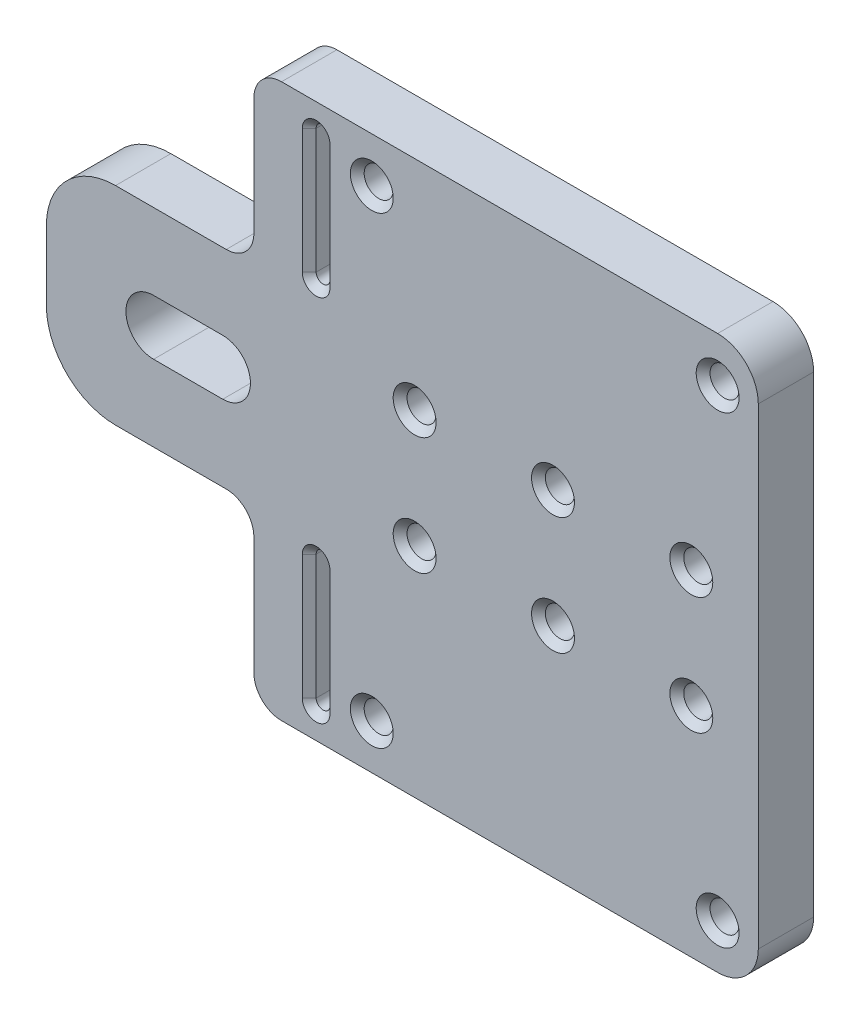
from build123d import *

# Parameters (mm, degrees)
MODEL_R            = 2.1
BOSS_EXTRU_1_DEPTH = 8
CHANFREIN1_SIZE    = 1


with BuildPart() as part:
    # Model → Boss.-Extru.1 (new body)
    with BuildSketch(Plane.XY):
        with BuildLine():
            Line((-24.192398664, -96.552630985), (-24.192398664, -106.552630985))
            ThreePointArc((-24.192398664, -106.552630985), (-21.263466476, -113.623698797), (-14.192398664, -116.552630985))
            Line((-14.192398664, -116.552630985), (1.807601336, -116.552630985))
            ThreePointArc((1.807601336, -116.552630985), (4.636028461, -117.72420386), (5.807601336, -120.552630985))
            Line((5.807601336, -120.552630985), (5.807601336, -137.552630985))
            ThreePointArc((5.807601336, -137.552630985), (6.979174211, -140.38105811), (9.807601336, -141.552630985))
            Line((9.807601336, -141.552630985), (72.853374331, -141.552630985))
            ThreePointArc((72.853374331, -141.552630985), (77.007626671, -139.831883325), (78.728374331, -135.677630985))
            Line((78.728374331, -135.677630985), (78.728374331, -67.427630985))
            ThreePointArc((78.728374331, -67.427630985), (77.007626671, -63.273378646), (72.853374331, -61.552630985))
            Line((72.853374331, -61.552630985), (9.807601336, -61.552630985))
            ThreePointArc((9.807601336, -61.552630985), (6.979174211, -62.72420386), (5.807601336, -65.552630985))
            Line((5.807601336, -65.552630985), (5.807601336, -82.552630985))
            ThreePointArc((5.807601336, -82.552630985), (4.636028461, -85.38105811), (1.807601336, -86.552630985))
            Line((1.807601336, -86.552630985), (-14.192398664, -86.552630985))
            ThreePointArc((-14.192398664, -86.552630985), (-21.263466476, -89.481563173), (-24.192398664, -96.552630985))
        make_face()
        with Locations((22.853374331, -68.052630985)):
            Circle(MODEL_R, mode=Mode.SUBTRACT)
        with Locations((72.853374331, -68.052630985)):
            Circle(MODEL_R, mode=Mode.SUBTRACT)
        with Locations((29.048492507, -93.052630985)):
            Circle(MODEL_R, mode=Mode.SUBTRACT)
        with Locations((29.048492507, -110.052630985)):
            Circle(MODEL_R, mode=Mode.SUBTRACT)
        with Locations((49.048492507, -93.052630985)):
            Circle(MODEL_R, mode=Mode.SUBTRACT)
        with Locations((49.048492507, -110.052630985)):
            Circle(MODEL_R, mode=Mode.SUBTRACT)
        with Locations((69.048492507, -93.052630985)):
            Circle(MODEL_R, mode=Mode.SUBTRACT)
        with Locations((69.048492507, -110.052630985)):
            Circle(MODEL_R, mode=Mode.SUBTRACT)
        with Locations((22.853374331, -135.052630985)):
            Circle(MODEL_R, mode=Mode.SUBTRACT)
        with Locations((72.853374331, -135.052630985)):
            Circle(MODEL_R, mode=Mode.SUBTRACT)
        with BuildLine():
            Line((15.807601336, -137.214613672), (15.807601336, -119.214613672))
            ThreePointArc((15.807601336, -119.214613672), (14.807601336, -118.214613672), (13.807601336, -119.214613672))
            Line((13.807601336, -119.214613672), (13.807601336, -137.214613672))
            ThreePointArc((13.807601336, -137.214613672), (14.807601336, -138.214613672), (15.807601336, -137.214613672))
        make_face(mode=Mode.SUBTRACT)
        with BuildLine():
            Line((15.807601336, -65.890648299), (15.807601336, -83.890648299))
            ThreePointArc((15.807601336, -83.890648299), (14.807601336, -84.890648299), (13.807601336, -83.890648299))
            Line((13.807601336, -83.890648299), (13.807601336, -65.890648299))
            ThreePointArc((13.807601336, -65.890648299), (14.807601336, -64.890648299), (15.807601336, -65.890648299))
        make_face(mode=Mode.SUBTRACT)
        with BuildLine():
            Line((-8.692398664, -97.552630985), (1.307601336, -97.552630985))
            ThreePointArc((1.307601336, -97.552630985), (5.307601336, -101.552630985), (1.307601336, -105.552630985))
            Line((1.307601336, -105.552630985), (-8.692398664, -105.552630985))
            ThreePointArc((-8.692398664, -105.552630985), (-12.692398664, -101.552630985), (-8.692398664, -97.552630985))
        make_face(mode=Mode.SUBTRACT)
    extrude(amount=BOSS_EXTRU_1_DEPTH)

    # Chanfrein1
    chanfrein1_edges = [part.edges().sort_by_distance(p)[0] for p in [
        (14.807601336, -118.214613672, 0),
        (13.807601336, -128.214613672, 0),
        (14.807601336, -138.214613672, 0),
        (15.807601336, -128.214613672, 0),
        (14.807601336, -118.214613672, 8),
        (13.807601336, -128.214613672, 8),
        (14.807601336, -138.214613672, 8),
        (15.807601336, -128.214613672, 8),
        (20.753374331, -68.052630985, 8),
        (70.753374331, -68.052630985, 8),
        (26.948492507, -93.052630985, 8),
        (26.948492507, -110.052630985, 8),
        (46.948492507, -93.052630985, 8),
        (46.948492507, -110.052630985, 8),
        (66.948492507, -93.052630985, 8),
        (66.948492507, -110.052630985, 8),
        (20.753374331, -135.052630985, 8),
        (70.753374331, -135.052630985, 8),
        (14.807601336, -64.890648299, 0),
        (13.807601336, -74.890648299, 0),
        (14.807601336, -84.890648299, 0),
        (15.807601336, -74.890648299, 0),
        (14.807601336, -64.890648299, 8),
        (13.807601336, -74.890648299, 8),
        (14.807601336, -84.890648299, 8),
        (15.807601336, -74.890648299, 8),
    ]]
    chamfer(chanfrein1_edges, length=CHANFREIN1_SIZE)


solid = part.part
